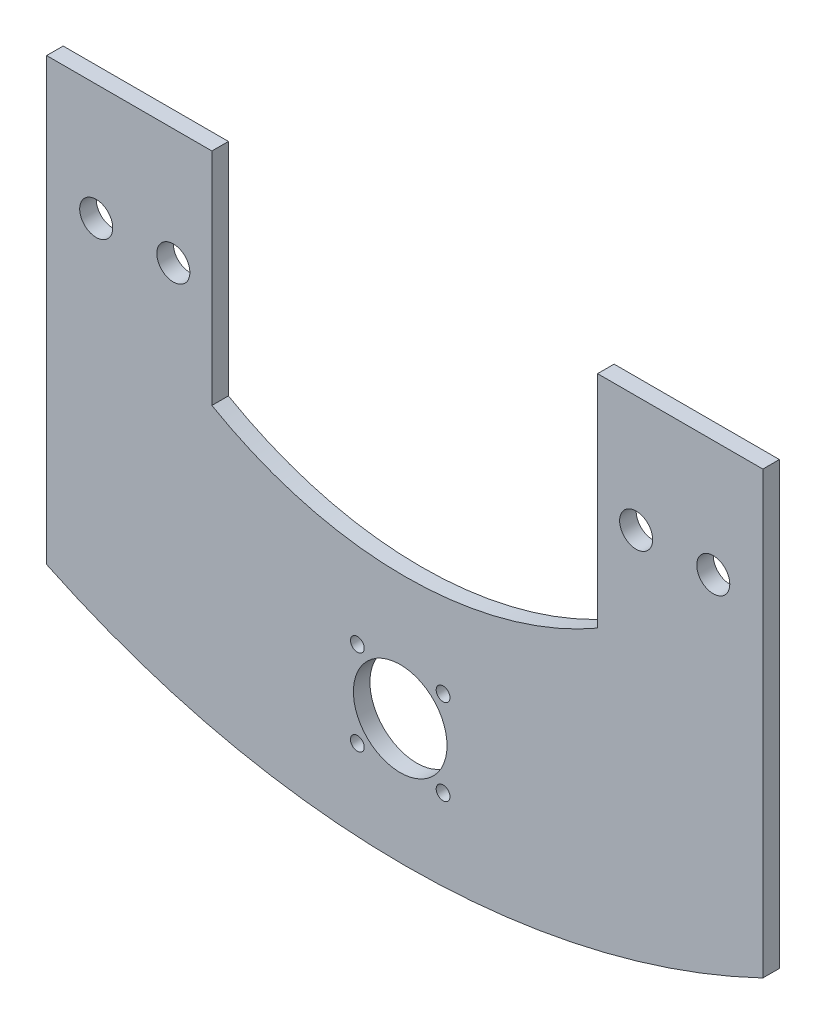
from build123d import *

# Parameters (mm, degrees)
SKETCH1_R           = 3
BOSS_EXTRUDE2_DEPTH = 3
SKETCH4_R           = 1.25
SKETCH4_R_2         = 8.5
CUT_EXTRUDE2_DEPTH  = 10


with BuildPart() as part:
    # Sketch1 → Boss-Extrude2 (new body)
    with BuildSketch(Plane.XY):
        with BuildLine():
            Line((-34.17966517, 1.656542757), (-34.17966517, 41.656542757))
            Line((-34.17966517, 41.656542757), (-64.17966517, 41.656542757))
            Line((-64.17966517, 41.656542757), (-64.17966517, -38.343457243))
            ThreePointArc((-64.17966517, -38.343457243), (0.82033483, -53.158398897), (65.82033483, -38.343457243))
            Line((65.82033483, -38.343457243), (65.82033483, 41.656542757))
            Line((65.82033483, 41.656542757), (35.82033483, 41.656542757))
            Line((35.82033483, 41.656542757), (35.82033483, 1.656542757))
            ThreePointArc((35.82033483, 1.656542757), (0.82033483, -7.721678978), (-34.17966517, 1.656542757))
        make_face()
        with Locations((56.82033483, 20.554474708)):
            Circle(SKETCH1_R, mode=Mode.SUBTRACT)
        with Locations((42.82033483, 20.554474708)):
            Circle(SKETCH1_R, mode=Mode.SUBTRACT)
        with Locations((-55.17966517, 20.554474708)):
            Circle(SKETCH1_R, mode=Mode.SUBTRACT)
        with Locations((-41.17966517, 20.554474708)):
            Circle(SKETCH1_R, mode=Mode.SUBTRACT)
    extrude(amount=BOSS_EXTRUDE2_DEPTH)

    # Sketch4 → Cut-Extrude2 (cut)
    with BuildSketch(Plane.XY.offset(3)):
        with Locations((7.78, -22.696934593)):
            Circle(SKETCH4_R)
        with Locations((7.78, -38.256934593)):
            Circle(SKETCH4_R)
        with Locations((-7.78, -38.256934593)):
            Circle(SKETCH4_R)
        with Locations((-7.78, -22.696934593)):
            Circle(SKETCH4_R)
        with Locations((0, -30.476934593)):
            Circle(SKETCH4_R_2)
    extrude(amount=-CUT_EXTRUDE2_DEPTH, mode=Mode.SUBTRACT)


solid = part.part
